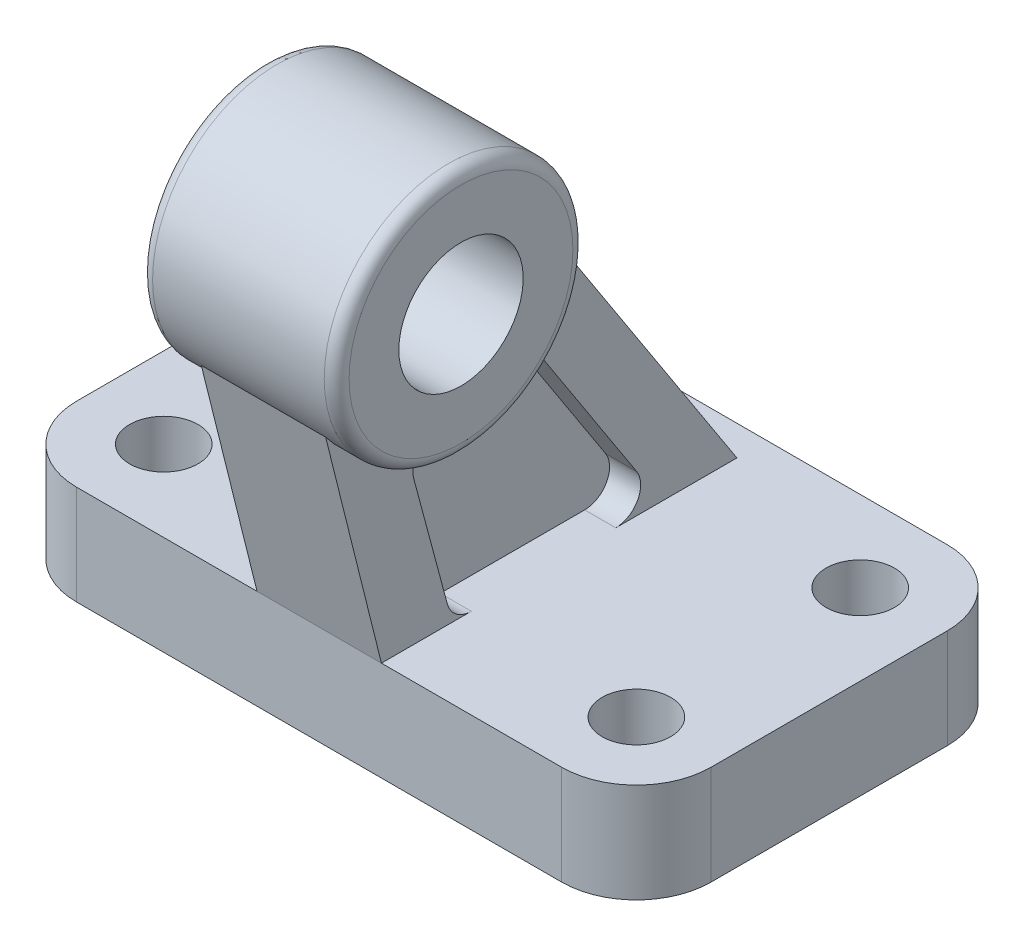
from build123d import *

# Parameters (mm, degrees)
SKETCH1_R                = 2.75
BOSS_EXTRUDE1_DEPTH      = 8
BOSS_EXTRUDE2_DEPTH      = 5
BOSS_EXTRUDE2_DEPTH_BACK = 5
CUT_EXTRUDE1_DEPTH       = 2.5
CUT_EXTRUDE2_DEPTH       = 2.5
CUT_EXTRUDE3_DEPTH       = 3.5


with BuildPart() as part:
    # Sketch1 → Boss-Extrude1 (new body)
    with BuildSketch(Plane(origin=(0, 0, 0), x_dir=(1, 0, 0), z_dir=(0, 1, 0))):
        with BuildLine():
            Line((-19.5, -15.5), (19.5, -15.5))
            ThreePointArc((19.5, -15.5), (23.742640687, -13.742640687), (25.5, -9.5))
            Line((25.5, -9.5), (25.5, 9.5))
            ThreePointArc((25.5, 9.5), (23.742640687, 13.742640687), (19.5, 15.5))
            Line((19.5, 15.5), (-19.5, 15.5))
            ThreePointArc((-19.5, 15.5), (-23.742640687, 13.742640687), (-25.5, 9.5))
            Line((-25.5, 9.5), (-25.5, -9.5))
            ThreePointArc((-25.5, -9.5), (-23.742640687, -13.742640687), (-19.5, -15.5))
        make_face()
        with Locations((19, 9)):
            Circle(SKETCH1_R, mode=Mode.SUBTRACT)
        with Locations((19, -9)):
            Circle(SKETCH1_R, mode=Mode.SUBTRACT)
        with Locations((-19, 9)):
            Circle(SKETCH1_R, mode=Mode.SUBTRACT)
        with Locations((-19, -9)):
            Circle(SKETCH1_R, mode=Mode.SUBTRACT)
    extrude(amount=BOSS_EXTRUDE1_DEPTH)

    # Sketch2 → Boss-Extrude2 (add, two sides)
    with BuildSketch(Plane(origin=(0, 0, 0), x_dir=(0, 0, -1), z_dir=(1, 0, 0))) as boss_extrude2_sk:
        with BuildLine():
            Line((-20.35784849, 27.483766103), (-15.5, 8))
            Line((-15.5, 8), (13.085782237, 8))
            Line((13.085782237, 8), (-2.5, 32))
            ThreePointArc((-2.5, 32), (-9.670789904, 22.789963066), (-20.35784849, 27.483766103))
        make_face()
    extrude(amount=BOSS_EXTRUDE2_DEPTH)
    extrude(boss_extrude2_sk.sketch, amount=-BOSS_EXTRUDE2_DEPTH_BACK)

    # Sketch3 → Cut-Extrude1 (cut)
    with BuildSketch(Plane(origin=(5, 0, 0), x_dir=(0, 0, -1), z_dir=(1, 0, 0))):
        with BuildLine():
            Line((-12.894702583, 19.52726585), (-10.203178684, 9.48236191))
            ThreePointArc((-10.203178684, 9.48236191), (-9.48884989, 8.413293319), (-8.271327032, 8))
            Line((-8.271327032, 8), (3.344242354, 8))
            ThreePointArc((3.344242354, 8), (5.101876579, 9.045682479), (5.02158349, 11.08927807))
            Line((5.02158349, 11.08927807), (-3.061203443, 23.535678478))
            ThreePointArc((-3.061203443, 23.535678478), (-4.395332352, 24.416731692), (-5.948787149, 24.038667007))
            ThreePointArc((-5.948787149, 24.038667007), (-8.400375652, 22.670332023), (-11.135709109, 22.03741995))
            ThreePointArc((-11.135709109, 22.03741995), (-12.60073654, 21.192654231), (-12.894702583, 19.52726585))
        make_face()
    extrude(amount=-CUT_EXTRUDE1_DEPTH, mode=Mode.SUBTRACT)

    # Sketch4 → Cut-Extrude2 (cut)
    with BuildSketch(Plane(origin=(-5, 0, 0), x_dir=(0, 0, -1), z_dir=(1, 0, 0))):
        with BuildLine():
            Line((-12.894702583, 19.52726585), (-10.203178684, 9.48236191))
            ThreePointArc((-10.203178684, 9.48236191), (-9.48884989, 8.413293319), (-8.271327032, 8))
            Line((-8.271327032, 8), (3.344242354, 8))
            ThreePointArc((3.344242354, 8), (5.101876579, 9.045682479), (5.02158349, 11.08927807))
            Line((5.02158349, 11.08927807), (-3.061203443, 23.535678478))
            ThreePointArc((-3.061203443, 23.535678478), (-4.395332352, 24.416731692), (-5.948787149, 24.038667007))
            ThreePointArc((-5.948787149, 24.038667007), (-8.400375652, 22.670332023), (-11.135709109, 22.03741995))
            ThreePointArc((-11.135709109, 22.03741995), (-12.60073654, 21.192654231), (-12.894702583, 19.52726585))
        make_face()
    extrude(amount=CUT_EXTRUDE2_DEPTH, mode=Mode.SUBTRACT)

    # Sketch5 → Revolve1 (revolve)
    with BuildSketch(Plane.XY.offset(12)):
        with BuildLine():
            Line((-7.9, 41), (-7.9, 37))
            Line((-7.9, 37), (7.9, 37))
            Line((7.9, 37), (7.9, 41))
            ThreePointArc((7.9, 41), (7.607106781, 41.707106781), (6.9, 42))
            Line((6.9, 42), (-6.9, 42))
            ThreePointArc((-6.9, 42), (-7.607106781, 41.707106781), (-7.9, 41))
        make_face()
    revolve(axis=Axis((7.9, 32, 12), (-1, 0, 0)))

    # Sketch6 → Cut-Extrude3 (cut)
    with BuildSketch(Plane(origin=(0, 0, 0), x_dir=(1, 0, 0), z_dir=(0, 1, 0))):
        with BuildLine():
            Line((-20.5, 0.013899622), (-20.5, -0.013899622))
            ThreePointArc((-20.5, -0.013899622), (-19.952966315, -1.388268164), (-18.611111111, -2.010810817))
            ThreePointArc((-18.611111111, -2.010810817), (-14.190149162, -3.914202627), (-12.04334407, -8.222222222))
            ThreePointArc((-12.04334407, -8.222222222), (-11.389061423, -9.490711985), (-10.05572809, -10))
            Line((-10.05572809, -10), (10.05572809, -10))
            ThreePointArc((10.05572809, -10), (11.389061423, -9.490711985), (12.04334407, -8.222222222))
            ThreePointArc((12.04334407, -8.222222222), (14.190149162, -3.914202627), (18.611111111, -2.010810817))
            ThreePointArc((18.611111111, -2.010810817), (19.952966315, -1.388268164), (20.5, -0.013899622))
            Line((20.5, -0.013899622), (20.5, 0.013899622))
            ThreePointArc((20.5, 0.013899622), (19.952966315, 1.388268164), (18.611111111, 2.010810817))
            ThreePointArc((18.611111111, 2.010810817), (14.190149162, 3.914202627), (12.04334407, 8.222222222))
            ThreePointArc((12.04334407, 8.222222222), (11.389061423, 9.490711985), (10.05572809, 10))
            Line((10.05572809, 10), (-10.05572809, 10))
            ThreePointArc((-10.05572809, 10), (-11.389061423, 9.490711985), (-12.04334407, 8.222222222))
            ThreePointArc((-12.04334407, 8.222222222), (-14.190149162, 3.914202627), (-18.611111111, 2.010810817))
            ThreePointArc((-18.611111111, 2.010810817), (-19.952966315, 1.388268164), (-20.5, 0.013899622))
        make_face()
    extrude(amount=CUT_EXTRUDE3_DEPTH, mode=Mode.SUBTRACT)


solid = part.part
